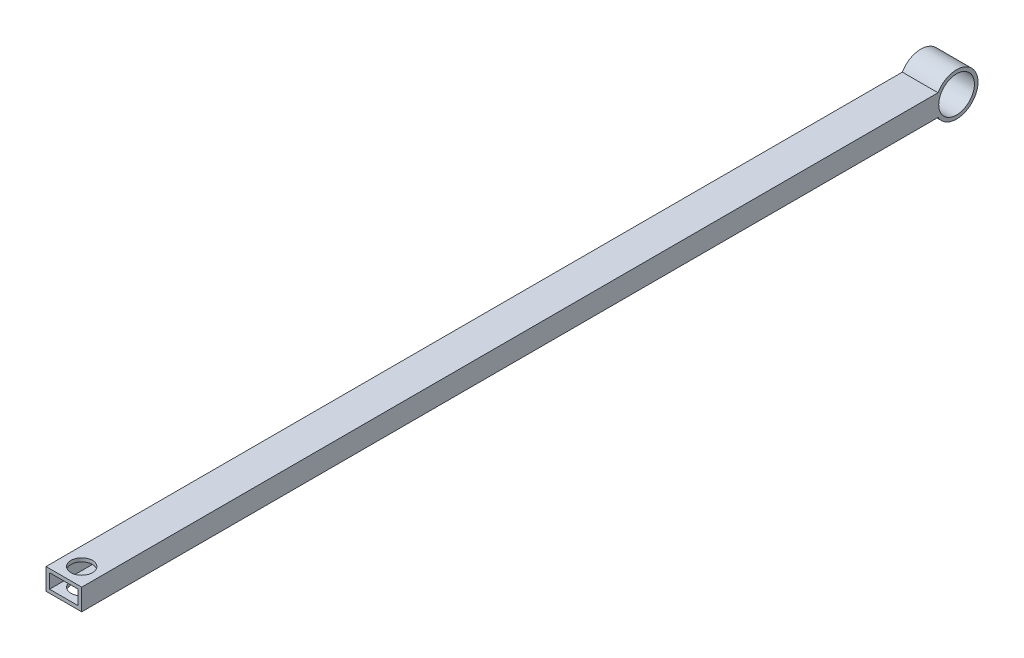
from build123d import *

# Parameters (mm, degrees)
SKETCH1_W               = 10
SKETCH1_H               = 6
BOSS_EXTRUDE1_DEPTH     = 250
SKETCH3_R               = 3
CUT_EXTRUDE2_DEPTH      = 249
CUT_EXTRUDE2_DEPTH_BACK = 249
SKETCH2_W               = 8
SKETCH2_H               = 4
CUT_EXTRUDE4_DEPTH      = 251
CUT_EXTRUDE4_DEPTH_BACK = 1
SKETCH7_R               = 6
BOSS_EXTRUDE2_DEPTH     = 10
SKETCH9_R               = 5
CUT_EXTRUDE7_DEPTH      = 1
CUT_EXTRUDE7_DEPTH_BACK = 11


with BuildPart() as part:
    # Sketch1 → Boss-Extrude1 (new body)
    with BuildSketch(Plane.XY):
        Rectangle(SKETCH1_W, SKETCH1_H)
    extrude(amount=BOSS_EXTRUDE1_DEPTH)

    # Sketch3 → Cut-Extrude2 (cut, two sides)
    with BuildSketch(Plane(origin=(0, 0, 0), x_dir=(1, 0, 0), z_dir=(0, 1, 0))) as cut_extrude2_sk:
        with Locations((0, -245)):
            Circle(SKETCH3_R)
    extrude(amount=CUT_EXTRUDE2_DEPTH, mode=Mode.SUBTRACT)
    extrude(cut_extrude2_sk.sketch, amount=-CUT_EXTRUDE2_DEPTH_BACK, mode=Mode.SUBTRACT)

    # Sketch2 → Cut-Extrude4 (cut, two sides)
    with BuildSketch(Plane.XY) as cut_extrude4_sk:
        Rectangle(SKETCH2_W, SKETCH2_H)
    extrude(amount=CUT_EXTRUDE4_DEPTH, mode=Mode.SUBTRACT)
    extrude(cut_extrude4_sk.sketch, amount=-CUT_EXTRUDE4_DEPTH_BACK, mode=Mode.SUBTRACT)

    # Sketch7 → Boss-Extrude2 (add)
    with BuildSketch(Plane.ZY.offset(5)):
        with Locations((5, 0)):
            Circle(SKETCH7_R)
    extrude(amount=-BOSS_EXTRUDE2_DEPTH)

    # Sketch9 → Cut-Extrude7 (cut, two sides)
    with BuildSketch(Plane.ZY.offset(5)) as cut_extrude7_sk:
        with Locations((5, 0)):
            Circle(SKETCH9_R)
    extrude(amount=CUT_EXTRUDE7_DEPTH, mode=Mode.SUBTRACT)
    extrude(cut_extrude7_sk.sketch, amount=-CUT_EXTRUDE7_DEPTH_BACK, mode=Mode.SUBTRACT)


solid = part.part
